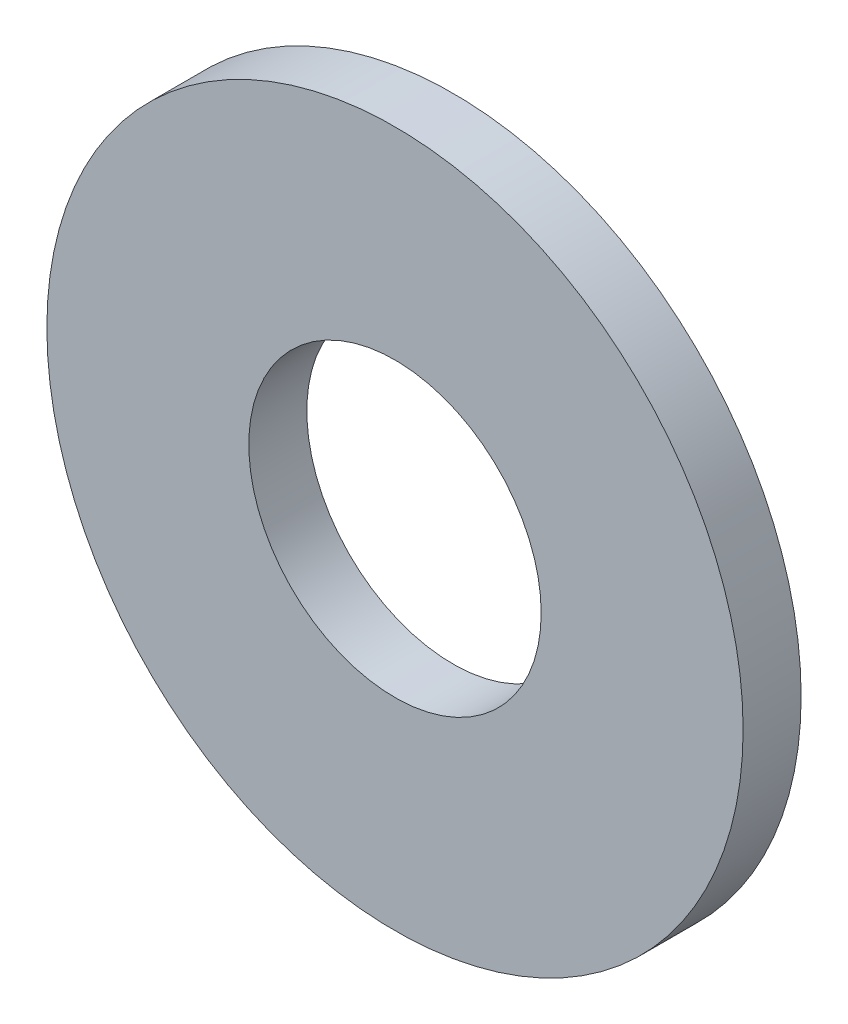
from build123d import *

# Parameters (mm, degrees)
SKETCH1_R           = 9.525
SKETCH1_R_2         = 4
BOSS_EXTRUDE1_DEPTH = 1.5875


with BuildPart() as part:
    # Sketch1 → Boss-Extrude1 (new body)
    with BuildSketch(Plane.XY):
        Circle(SKETCH1_R)
        Circle(SKETCH1_R_2, mode=Mode.SUBTRACT)
    extrude(amount=BOSS_EXTRUDE1_DEPTH)


solid = part.part
